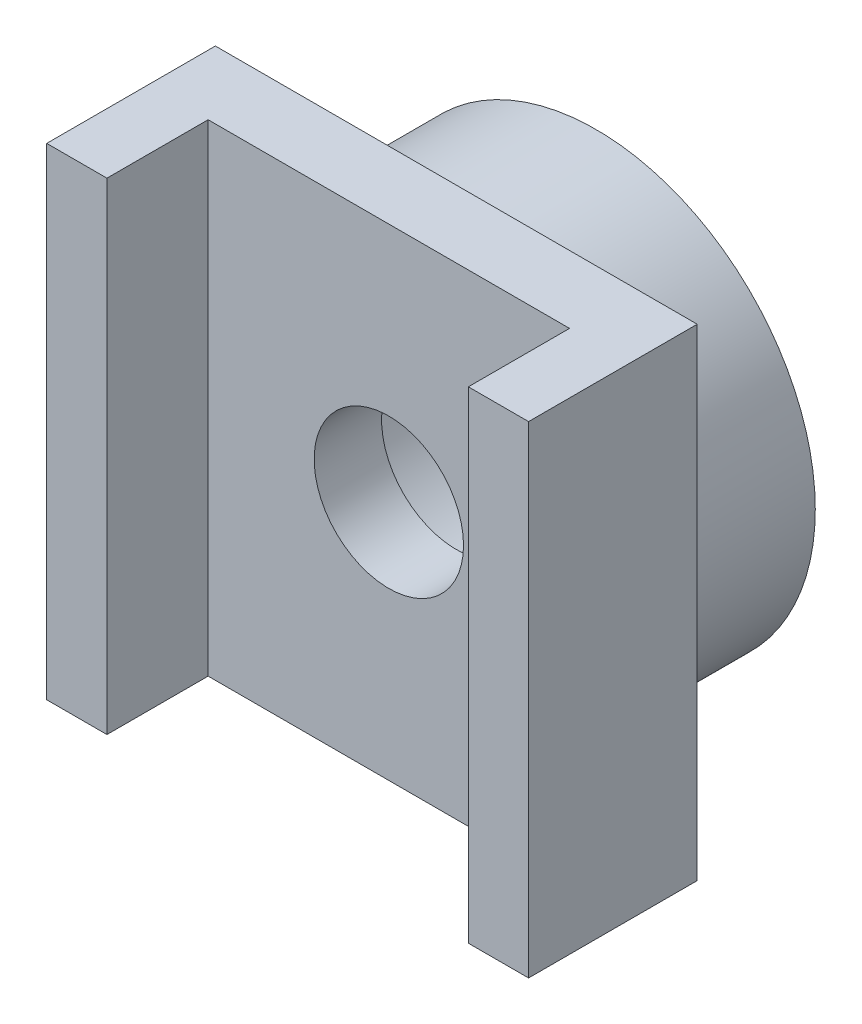
from build123d import *

# Parameters (mm, degrees)
SKETCH_1_R      = 4.55
SKETCH_1_R_2    = 2.8
EXTRUDE_1_DEPTH = 2.9
SKETCH_2_W      = 10
SKETCH_2_H      = 10
SKETCH_2_R      = 1.55
EXTRUDE_2_DEPTH = 1.4
SKETCH_3_W      = 1.25
SKETCH_3_H      = 10
EXTRUDE_3_DEPTH = 2.1


with BuildPart() as part:
    # Эскиз1 → Вытянуть1 (new body)
    with BuildSketch(Plane.XY):
        Circle(SKETCH_1_R)
        Circle(SKETCH_1_R_2, mode=Mode.SUBTRACT)
    extrude(amount=EXTRUDE_1_DEPTH)

    # Эскиз2 → Вытянуть2 (add)
    with BuildSketch(Plane.XY.offset(2.9)):
        Rectangle(SKETCH_2_W, SKETCH_2_H)
        Circle(SKETCH_2_R, mode=Mode.SUBTRACT)
    extrude(amount=EXTRUDE_2_DEPTH)

    # Эскиз3 → Вытянуть3 (add)
    with BuildSketch(Plane.XY.offset(4.3)):
        with Locations((-4.375, 0)):
            Rectangle(SKETCH_3_W, SKETCH_3_H)
        with Locations((4.375, 0)):
            Rectangle(SKETCH_3_W, SKETCH_3_H)
    extrude(amount=EXTRUDE_3_DEPTH)


solid = part.part
